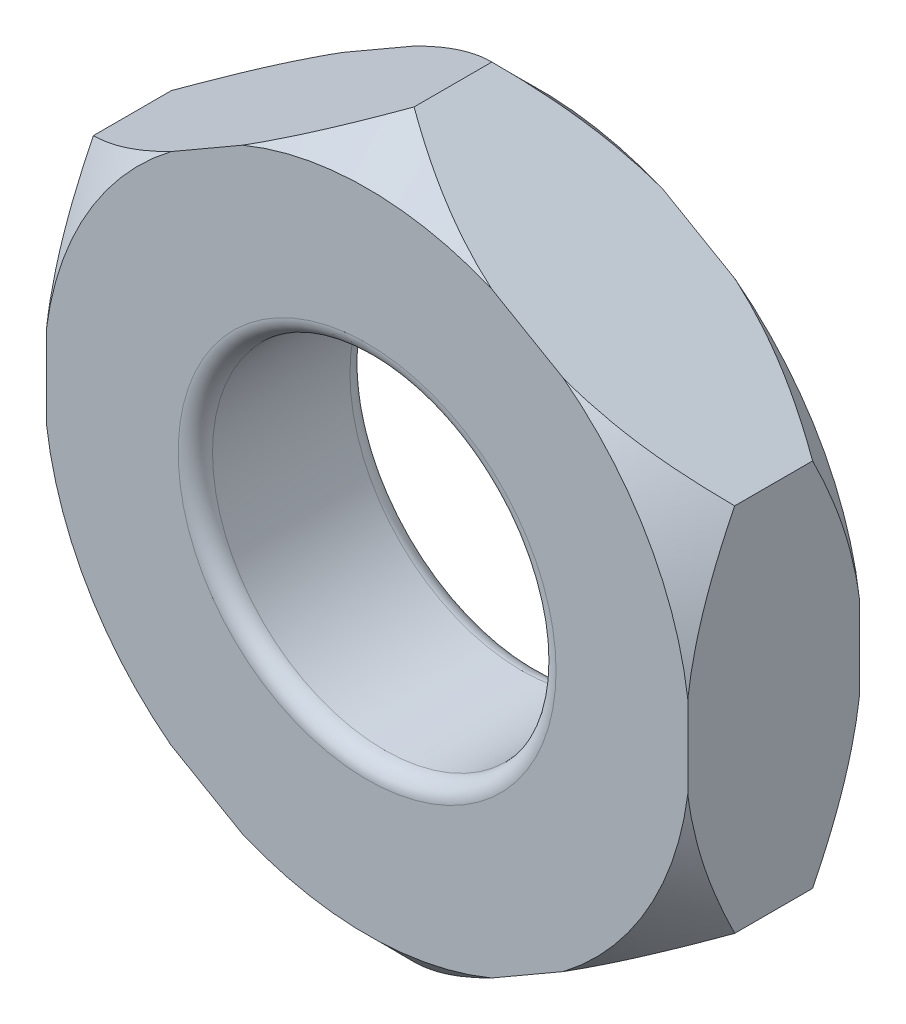
from build123d import *

# Parameters (mm, degrees)
EXTRUDE_2_DEPTH     = 1.5
SKETCH_2_R          = 1.5
CUT_EXTRUDE_1_DEPTH = 1.5
FILLET_3_R          = 0.15


with BuildPart() as part:
    # 草图1 → 凸台-拉伸2 (new body)
    with BuildSketch(Plane.XY):
        Polygon((0, 3.233161507), (-2.8, 1.616580754), (-2.8, -1.616580754), (0, -3.233161507), (2.8, -1.616580754), (2.8, 1.616580754), align=None)
    extrude(amount=-EXTRUDE_2_DEPTH)

    # 草图2 → 切除-拉伸1 (cut)
    with BuildSketch(Plane.XY):
        Circle(SKETCH_2_R)
    extrude(amount=-CUT_EXTRUDE_1_DEPTH, mode=Mode.SUBTRACT)

    # 圆角3
    fillet_3_edges = [part.edges().sort_by_distance(p)[0] for p in [
        (-1.5, 0, -1.5),
        (-1.5, 0, 0),
    ]]
    fillet(fillet_3_edges, radius=FILLET_3_R)

    # 草图3 → 切除-旋转1 (revolve, cut)
    with BuildSketch(Plane(origin=(0, 0, 0), x_dir=(0, 0, -1), z_dir=(1, 0, 0))):
        Polygon((0, 3.233161507), (0.41, 3.233161507), (0, 2.823161507), align=None)
        Polygon((1.5, 3.233161507), (1.09, 3.233161507), (1.5, 2.823161507), align=None)
    revolve(axis=Axis((0, 0, 0), (0, 0, -1)), mode=Mode.SUBTRACT)


solid = part.part
